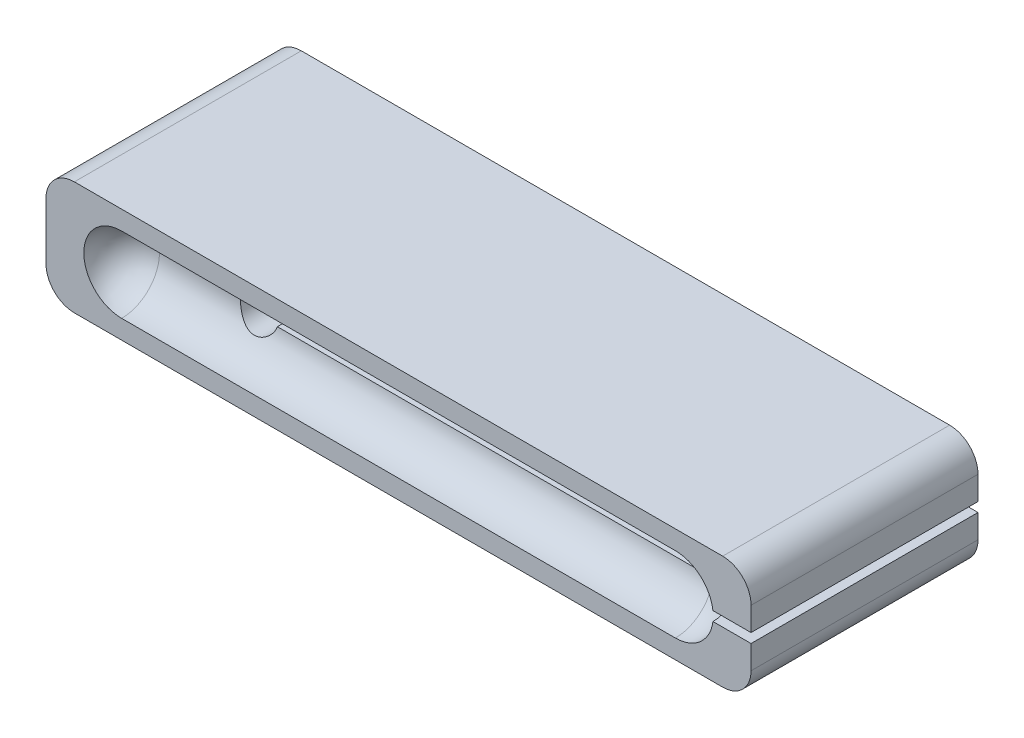
from build123d import *

# Parameters (mm, degrees)
BOSS_EXTRUDE1_DEPTH = 76.2


with BuildPart() as part:
    # Sketch1 → Boss-Extrude1 (new body)
    with BuildSketch(Plane.XY):
        with BuildLine():
            Line((0, 20.6375), (0, 28.575))
            ThreePointArc((0, 28.575), (-2.789807909, 35.310192091), (-9.525, 38.1))
            Line((-9.525, 38.1), (-227.203, 38.1))
            ThreePointArc((-227.203, 38.1), (-233.938192091, 35.310192091), (-236.728, 28.575))
            Line((-236.728, 28.575), (-236.728, 9.525))
            ThreePointArc((-236.728, 9.525), (-233.938192091, 2.789807909), (-227.203, 0))
            Line((-227.203, 0), (-9.525, 0))
            ThreePointArc((-9.525, 0), (-2.789807909, 2.789807909), (0, 9.525))
            Line((0, 9.525), (0, 17.4625))
            Line((0, 17.4625), (-22.650369343, 17.4625))
            ThreePointArc((-22.650369343, 17.4625), (-25.4, 15.875), (-28.149630657, 17.4625))
            Line((-28.149630657, 17.4625), (-171.651638938, 17.4625))
            ThreePointArc((-171.651638938, 17.4625), (-184.15, 19.05), (-171.651638938, 20.6375))
            Line((-171.651638938, 20.6375), (-28.149630657, 20.6375))
            ThreePointArc((-28.149630657, 20.6375), (-25.4, 22.225), (-22.650369343, 20.6375))
            Line((-22.650369343, 20.6375), (0, 20.6375))
        make_face()
    extrude(amount=BOSS_EXTRUDE1_DEPTH)

    # Sketch2 → Cut-Revolve1 (revolve, cut)
    with BuildSketch(Plane.XY.offset(76.2)):
        with BuildLine():
            Line((-211.328, 31.75), (-25.4, 31.75))
            ThreePointArc((-25.4, 31.75), (-16.419743879, 28.030256121), (-12.7, 19.05))
            Line((-12.7, 19.05), (-224.028, 19.05))
            ThreePointArc((-224.028, 19.05), (-220.308256121, 28.030256121), (-211.328, 31.75))
        make_face()
    revolve(axis=Axis((-224.028, 19.05, 76.2), (1, 0, 0)), mode=Mode.SUBTRACT)

    # Sketch4 → Cut-Revolve3 (revolve, cut)
    with BuildSketch(Plane(origin=(0, 0, 0), x_dir=(-1, 0, 0), z_dir=(0, 0, -1))):
        with BuildLine():
            Line((25.4, 31.75), (211.328, 31.75))
            ThreePointArc((211.328, 31.75), (220.308256121, 28.030256121), (224.028, 19.05))
            Line((224.028, 19.05), (12.7, 19.05))
            ThreePointArc((12.7, 19.05), (16.419743879, 28.030256121), (25.4, 31.75))
        make_face()
    revolve(axis=Axis((-224.028, 19.05, 0), (1, 0, 0)), mode=Mode.SUBTRACT)


solid = part.part
